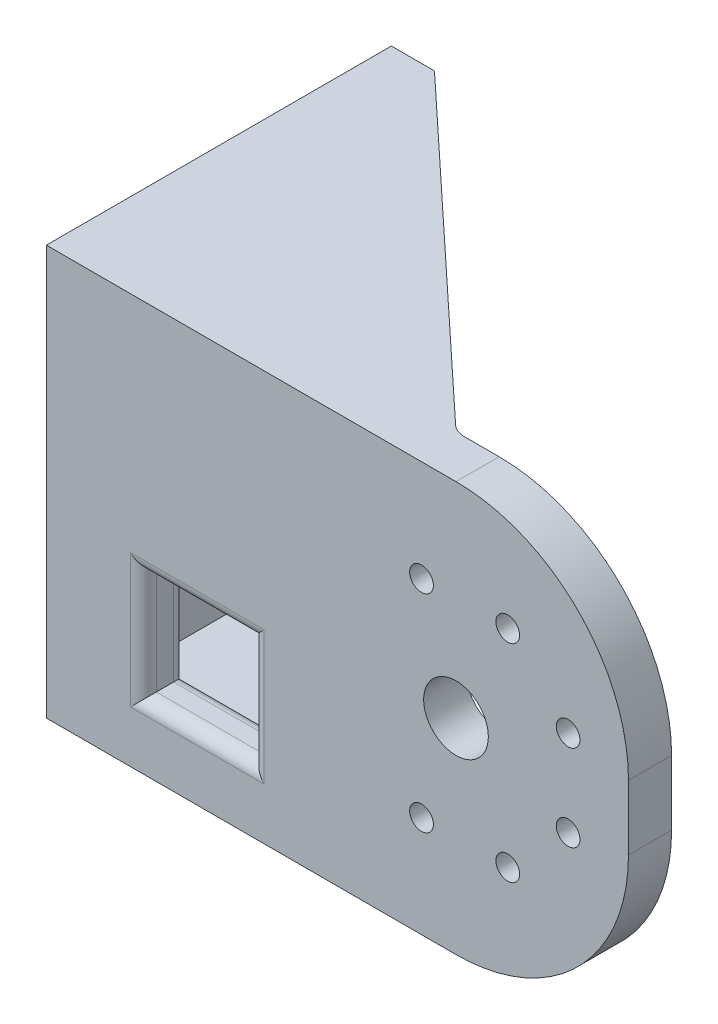
from build123d import *

# Parameters (mm, degrees)
SKETCH3_R           = 7.5
SKETCH3_R_2         = 2.75
BOSS_EXTRUDE1_DEPTH = 10
SKETCH4_W           = 10
SKETCH4_H           = 95
BOSS_EXTRUDE2_DEPTH = 70
SKETCH8_R           = 7.5
SKETCH8_R_2         = 2.75
CUT_EXTRUDE2_DEPTH  = 43.8
BOSS_EXTRUDE3_DEPTH = 10
FILLET1_R           = 5
SKETCH11_W          = 25
SKETCH11_H          = 25
CUT_EXTRUDE3_DEPTH  = 11
FILLET3_R           = 3


with BuildPart() as part:
    # Sketch3 → Boss-Extrude1 (new body)
    with BuildSketch(Plane.XY):
        with BuildLine():
            Line((68.617133813, 80.05993294), (163.617133813, 80.05993294))
            ThreePointArc((163.617133813, 80.05993294), (191.90140506, 68.344204188), (203.617133813, 40.05993294))
            Line((203.617133813, 40.05993294), (203.617133813, 25.05993294))
            ThreePointArc((203.617133813, 25.05993294), (191.90140506, -3.224338307), (163.617133813, -14.94006706))
            Line((163.617133813, -14.94006706), (68.617133813, -14.94006706))
            Line((68.617133813, -14.94006706), (68.617133813, 80.05993294))
        make_face()
        with Locations((163.617133813, 32.55993294)):
            Circle(SKETCH3_R, mode=Mode.SUBTRACT)
        with Locations((189.617133813, 42.55993294)):
            Circle(SKETCH3_R_2, mode=Mode.SUBTRACT)
        with Locations((155.617133813, 56.55993294)):
            Circle(SKETCH3_R_2, mode=Mode.SUBTRACT)
        with Locations((175.617133813, 56.55993294)):
            Circle(SKETCH3_R_2, mode=Mode.SUBTRACT)
        with Locations((155.617133813, 8.55993294)):
            Circle(SKETCH3_R_2, mode=Mode.SUBTRACT)
        with Locations((175.617133813, 8.55993294)):
            Circle(SKETCH3_R_2, mode=Mode.SUBTRACT)
        with Locations((189.617133813, 22.55993294)):
            Circle(SKETCH3_R_2, mode=Mode.SUBTRACT)
    extrude(amount=BOSS_EXTRUDE1_DEPTH)

    # Sketch4 → Boss-Extrude2 (add)
    with BuildSketch(Plane(origin=(0, 0, 0), x_dir=(-1, 0, 0), z_dir=(0, 0, -1))):
        with Locations((-73.617133813, 32.55993294)):
            Rectangle(SKETCH4_W, SKETCH4_H)
    extrude(amount=BOSS_EXTRUDE2_DEPTH)

    # Sketch8 → Cut-Extrude2 (cut)
    with BuildSketch(Plane.ZY.offset(-68.617133813)):
        with Locations((-40, 32.55993294)):
            Circle(SKETCH8_R)
        with Locations((-56.167891819, 25.862972874)):
            Circle(SKETCH8_R_2)
        with Locations((-56.167891819, 39.256893006)):
            Circle(SKETCH8_R_2)
        with Locations((-46.696960066, 48.727824759)):
            Circle(SKETCH8_R_2)
        with Locations((-33.303039934, 48.727824759)):
            Circle(SKETCH8_R_2)
        with Locations((-23.832108181, 39.256893006)):
            Circle(SKETCH8_R_2)
        with Locations((-23.832108181, 25.862972874)):
            Circle(SKETCH8_R_2)
        with Locations((-33.303039934, 16.392041121)):
            Circle(SKETCH8_R_2)
        with Locations((-46.696960066, 16.392041121)):
            Circle(SKETCH8_R_2)
    extrude(amount=-CUT_EXTRUDE2_DEPTH, mode=Mode.SUBTRACT)

    # Sketch9 → Boss-Extrude3 (add)
    with BuildSketch(Plane.XZ.offset(14.94006706)):
        Polygon((78.617133813, -70), (153.617133813, 0), (78.617133813, 0), align=None)
    boss_extrude3 = extrude(amount=-BOSS_EXTRUDE3_DEPTH)

    # Mirror1: Boss-Extrude3 across plane
    add(boss_extrude3.mirror(Plane(origin=(0, 32.55993294, 0), x_dir=(0, 0, 1), z_dir=(0, -1, 0))))

    # Fillet1
    fillet1_edges = [part.edges().sort_by_distance(p)[0] for p in [
        (153.617133813, -9.94006706, 0),
        (153.617133813, 75.05993294, 0),
    ]]
    fillet(fillet1_edges, radius=FILLET1_R)

    # Sketch11 → Cut-Extrude3 (cut, through all)
    with BuildSketch(Plane(origin=(0, 0, 0), x_dir=(-1, 0, 0), z_dir=(0, 0, -1))):
        with Locations((-103.617133813, 12.55993294)):
            Rectangle(SKETCH11_W, SKETCH11_H)
    extrude(amount=-CUT_EXTRUDE3_DEPTH, mode=Mode.SUBTRACT)

    # Fillet3
    fillet3_edges = [part.edges().sort_by_distance(p)[0] for p in [
        (91.117133813, 12.55993294, 10),
        (103.617133813, 0.05993294, 10),
        (116.117133813, 12.55993294, 10),
        (103.617133813, 25.05993294, 10),
        (91.117133813, 12.55993294, 0),
        (103.617133813, 25.05993294, 0),
        (116.117133813, 12.55993294, 0),
        (103.617133813, 0.05993294, 0),
    ]]
    fillet(fillet3_edges, radius=FILLET3_R)


solid = part.part
